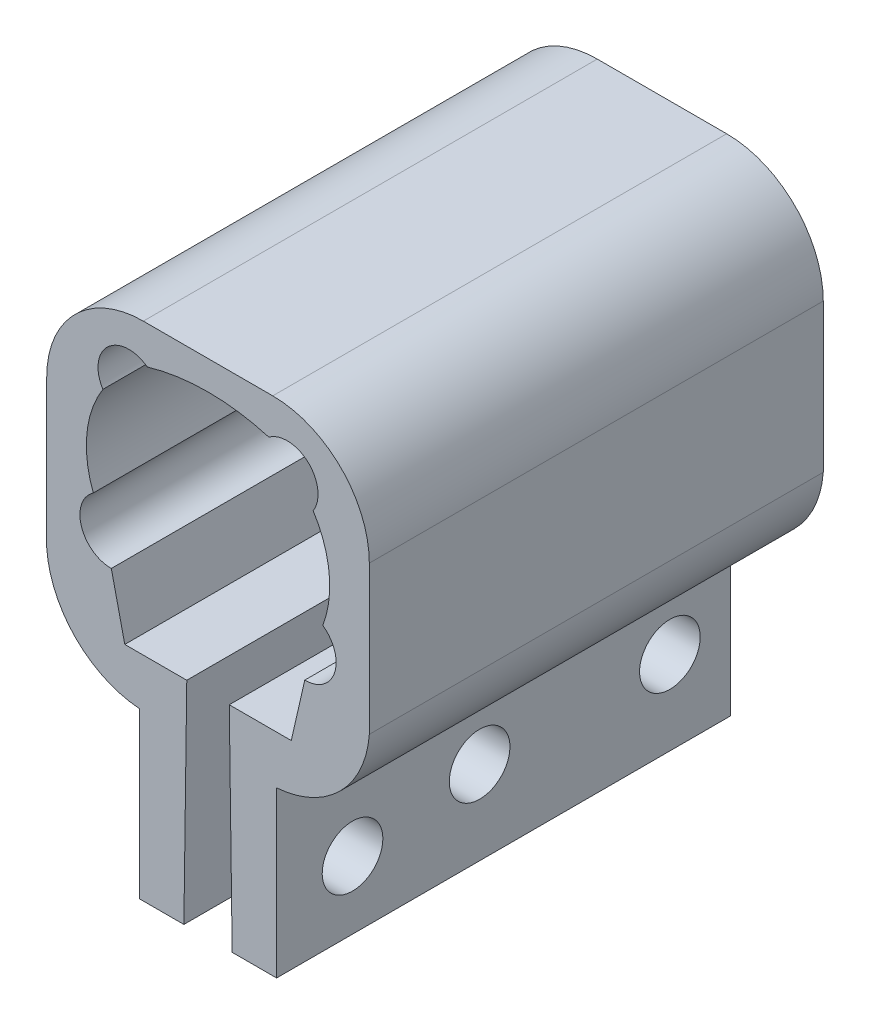
from build123d import *

# Parameters (mm, degrees)
BOSS_EXTRUDE1_DEPTH = 59.69
SKETCH31_R          = 3.9878
CUT_EXTRUDE1_DEPTH  = 31.226


with BuildPart() as part:
    # Sketch30 → Boss-Extrude1 (new body)
    with BuildSketch(Plane(origin=(0, 0, -44.196), x_dir=(-1, 0, 0), z_dir=(0, 0, -1))):
        with BuildLine():
            Line((-21.122639806, -11.230837818), (-19.351377941, -18.999086285))
            Line((-19.351377941, -18.999086285), (-11.19917043, -18.999086285))
            Line((-11.19917043, -18.999086285), (-11.58017043, -47.00394942))
            Line((-11.58017043, -47.00394942), (-17.42217043, -47.00394942))
            Line((-17.42217043, -47.00394942), (-17.42217043, -26.68394942))
            Line((-17.42217043, -26.68394942), (-17.42217043, -25.349086285))
            ThreePointArc((-17.42217043, -25.349086285), (-25.786020569, -21.520936424), (-29.61417043, -13.157086285))
            Line((-29.61417043, -13.157086285), (-29.61417043, 6.33605058))
            ThreePointArc((-29.61417043, 6.33605058), (-25.894426551, 15.316306701), (-16.91417043, 19.03605058))
            Line((-16.91417043, 19.03605058), (0.10382957, 19.03605058))
            ThreePointArc((0.10382957, 19.03605058), (9.084085691, 15.316306701), (12.80382957, 6.33605058))
            Line((12.80382957, 6.33605058), (12.80382957, -13.157086285))
            ThreePointArc((12.80382957, -13.157086285), (8.975679709, -21.520936424), (0.61182957, -25.349086285))
            Line((0.61182957, -25.349086285), (0.61182957, -26.68394942))
            Line((0.61182957, -26.68394942), (0.61182957, -47.00394942))
            Line((0.61182957, -47.00394942), (-5.23017043, -47.00394942))
            Line((-5.23017043, -47.00394942), (-5.61117043, -18.999086285))
            Line((-5.61117043, -18.999086285), (2.54103708, -18.999086285))
            Line((2.54103708, -18.999086285), (4.312298946, -11.230837818))
            ThreePointArc((4.312298946, -11.230837818), (8.246380302, -8.403768679), (6.679296605, -3.81971319))
            ThreePointArc((6.679296605, -3.81971319), (7.525853874, 2.546365897), (5.417372104, 8.61249537))
            ThreePointArc((5.417372104, 8.61249537), (4.777900298, 13.775697179), (-0.415899, 14.079054992))
            ThreePointArc((-0.415899, 14.079054992), (-8.40517043, 15.22605058), (-16.394441861, 14.079054992))
            ThreePointArc((-16.394441861, 14.079054992), (-21.588241548, 13.775696815), (-22.227712388, 8.612494473))
            ThreePointArc((-22.227712388, 8.612494473), (-24.336184911, 2.546364848), (-23.489636452, -3.819712493))
            ThreePointArc((-23.489636452, -3.819712493), (-25.056721349, -8.403768093), (-21.122639806, -11.230837818))
        make_face()
    extrude(amount=BOSS_EXTRUDE1_DEPTH)

    # Sketch31 → Cut-Extrude1 (cut, through all)
    with BuildSketch(Plane(origin=(17.42217043, 0, 0), x_dir=(0, 0, -1), z_dir=(1, 0, 0))):
        with Locations(Location((95.9104, -36.00574942, 0), (0, 0, 90))):  # turned: the seam where the file's is
            Circle(SKETCH31_R)
        with Locations(Location((70.8914, -36.00574942, 0), (0, 0, 90))):  # turned: the seam where the file's is
            Circle(SKETCH31_R)
        with Locations(Location((54.1782, -38.11394942, 0), (0, 0, 90))):  # turned: the seam where the file's is
            Circle(SKETCH31_R)
    extrude(amount=-CUT_EXTRUDE1_DEPTH, mode=Mode.SUBTRACT)


solid = part.part
